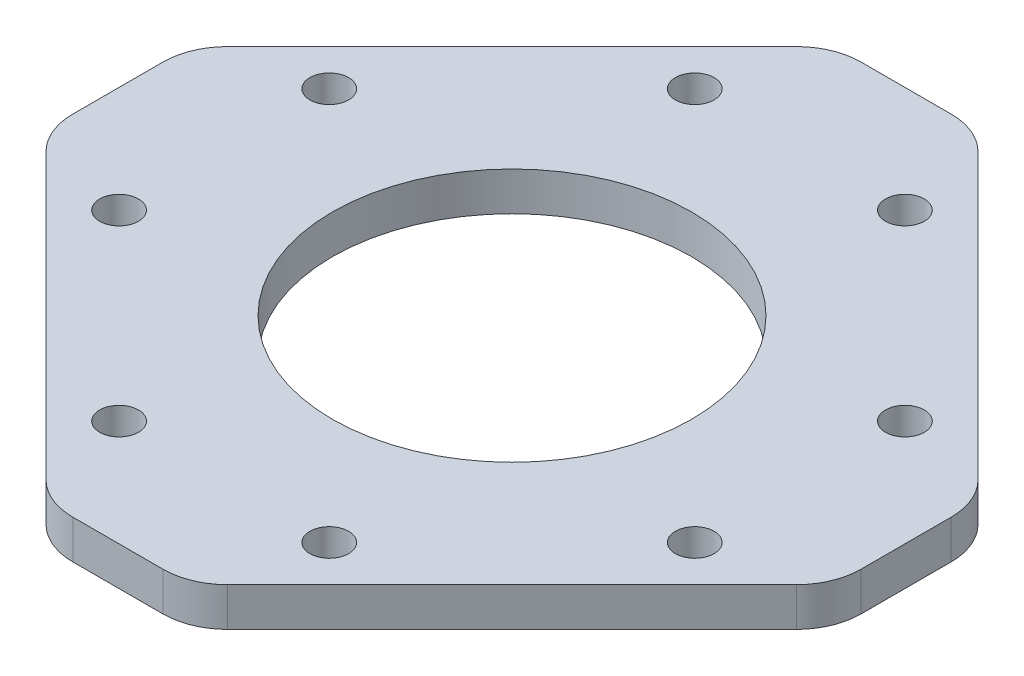
from build123d import *

# Parameters (mm, degrees)
SKETCH1_R           = 1.5
SKETCH1_R_2         = 13.9
BOSS_EXTRUDE1_DEPTH = 3


with BuildPart() as part:
    # Sketch1 → Boss-Extrude1 (new body)
    with BuildSketch(Plane(origin=(0, 0, 0), x_dir=(1, 0, 0), z_dir=(0, 1, 0))):
        with BuildLine():
            Line((3.491378029, 30.5), (-3.491378029, 30.5))
            ThreePointArc((-3.491378029, 30.5), (-5.40479519, 30.119397663), (-7.026911935, 29.035533906))
            Line((-7.026911935, 29.035533906), (-29.035533906, 7.026911935))
            ThreePointArc((-29.035533906, 7.026911935), (-30.119397663, 5.40479519), (-30.5, 3.491378029))
            Line((-30.5, 3.491378029), (-30.5, -3.491378029))
            ThreePointArc((-30.5, -3.491378029), (-30.119397663, -5.40479519), (-29.035533906, -7.026911935))
            Line((-29.035533906, -7.026911935), (-7.026911935, -29.035533906))
            ThreePointArc((-7.026911935, -29.035533906), (-5.40479519, -30.119397663), (-3.491378029, -30.5))
            Line((-3.491378029, -30.5), (3.491378029, -30.5))
            ThreePointArc((3.491378029, -30.5), (5.40479519, -30.119397663), (7.026911935, -29.035533906))
            Line((7.026911935, -29.035533906), (29.035533906, -7.026911935))
            ThreePointArc((29.035533906, -7.026911935), (30.119397663, -5.40479519), (30.5, -3.491378029))
            Line((30.5, -3.491378029), (30.5, 3.491378029))
            ThreePointArc((30.5, 3.491378029), (30.119397663, 5.40479519), (29.035533906, 7.026911935))
            Line((29.035533906, 7.026911935), (7.026911935, 29.035533906))
            ThreePointArc((7.026911935, 29.035533906), (5.40479519, 30.119397663), (3.491378029, 30.5))
        make_face()
        with Locations((-8.131727984, -22.273863607)):
            Circle(SKETCH1_R, mode=Mode.SUBTRACT)
        with Locations((8.131727984, -22.273863607)):
            Circle(SKETCH1_R, mode=Mode.SUBTRACT)
        with Locations((22.273863607, -8.131727984)):
            Circle(SKETCH1_R, mode=Mode.SUBTRACT)
        with Locations((22.273863607, 8.131727984)):
            Circle(SKETCH1_R, mode=Mode.SUBTRACT)
        with Locations((8.131727984, 22.273863607)):
            Circle(SKETCH1_R, mode=Mode.SUBTRACT)
        with Locations((-8.131727984, 22.273863607)):
            Circle(SKETCH1_R, mode=Mode.SUBTRACT)
        with Locations((-22.273863607, -8.131727984)):
            Circle(SKETCH1_R, mode=Mode.SUBTRACT)
        with Locations((-22.273863607, 8.131727984)):
            Circle(SKETCH1_R, mode=Mode.SUBTRACT)
        Circle(SKETCH1_R_2, mode=Mode.SUBTRACT)
    extrude(amount=BOSS_EXTRUDE1_DEPTH)


solid = part.part
